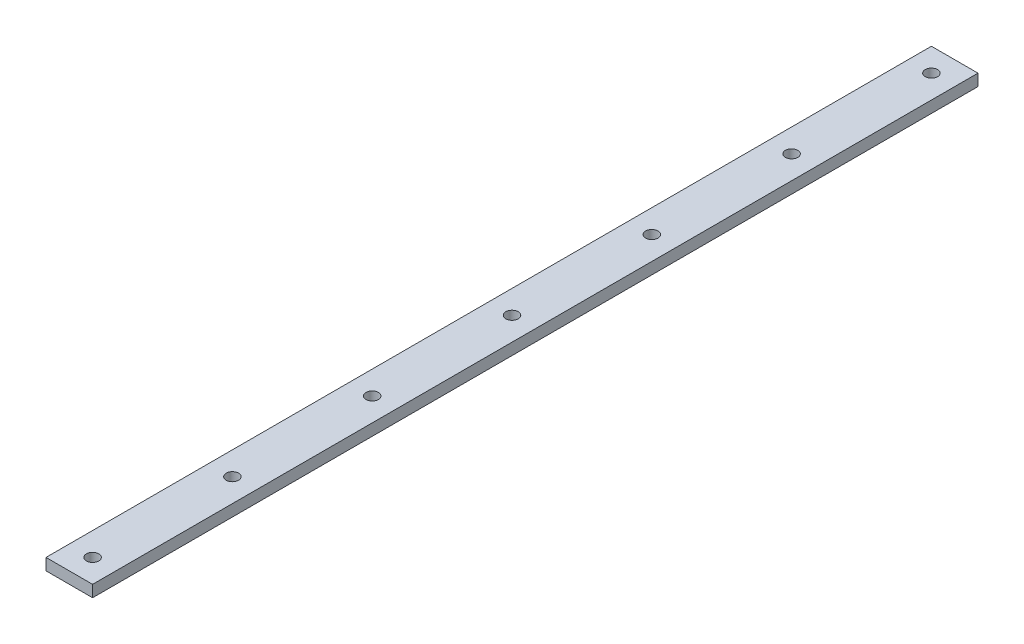
from build123d import *

# Parameters (mm, degrees)
SKETCH1_W               = 25.4
SKETCH1_H               = 482.6
BOSS_EXTRUDE1_DEPTH     = 6.35
F_1_4_CLEARANCE_HOLE1_D = 6.7564


with BuildPart() as part:
    # Sketch1 → Boss-Extrude1 (new body)
    with BuildSketch(Plane(origin=(0, 0, 0), x_dir=(1, 0, 0), z_dir=(0, 1, 0))):
        with Locations((-12.7, 241.3)):
            Rectangle(SKETCH1_W, SKETCH1_H)
    extrude(amount=BOSS_EXTRUDE1_DEPTH)

    # 1/4 Clearance Hole1 (through all)
    with Locations(Plane(origin=(0, 6.35, 0), x_dir=(1, 0, 0), z_dir=(0, 1, 0))):
        with Locations((-12.7, 12.7), (-12.7, 88.9), (-12.7, 165.1), (-12.7, 241.3), (-12.7, 317.5), (-12.7, 393.7), (-12.7, 469.9)):
            Hole(F_1_4_CLEARANCE_HOLE1_D / 2)


solid = part.part
